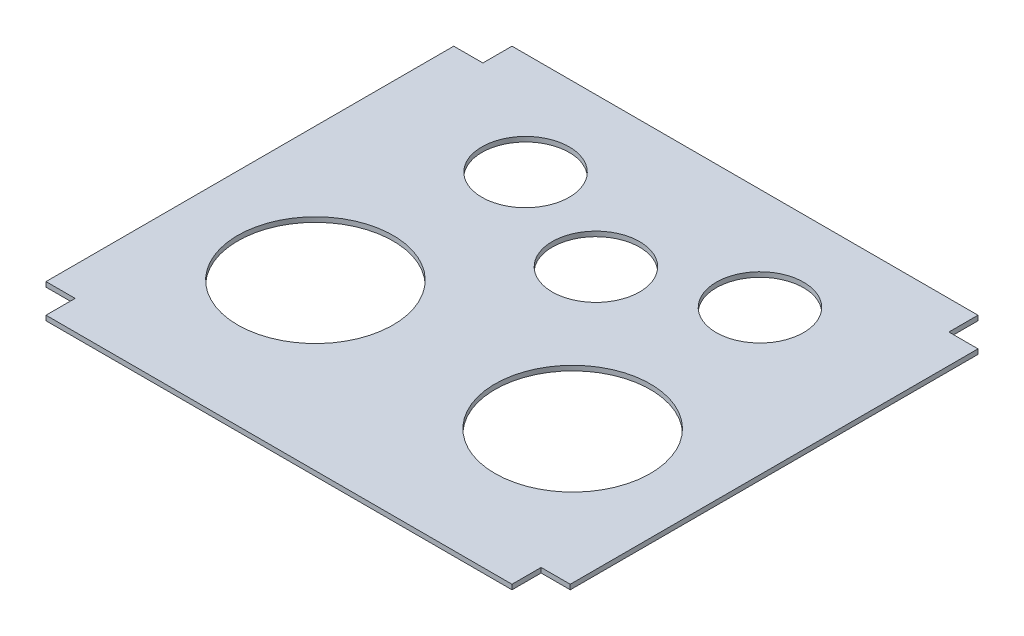
from build123d import *

# Parameters (mm, degrees)
SKETCH1_R           = 101.6
SKETCH1_R_2         = 57.15
BOSS_EXTRUDE1_DEPTH = 6.35


with BuildPart() as part:
    # Sketch1 → Boss-Extrude1 (new body)
    with BuildSketch(Plane(origin=(0, 0, 0), x_dir=(1, 0, 0), z_dir=(0, 1, 0))):
        Polygon((0, 0), (0, -38.1), (-609.6, -38.1), (-609.6, 0), (-647.7, 0), (-647.7, 533.4), (-609.6, 533.4), (-609.6, 571.5), (0, 571.5), (0, 533.4), (38.1, 533.4), (38.1, 0), align=None)
        with Locations((-473.075, 177.8)):
            Circle(SKETCH1_R, mode=Mode.SUBTRACT)
        with Locations((-136.525, 177.8)):
            Circle(SKETCH1_R, mode=Mode.SUBTRACT)
        with Locations((-304.8, 376.459625679)):
            Circle(SKETCH1_R_2, mode=Mode.SUBTRACT)
        with Locations((-151.485932589, 437.719781848)):
            Circle(SKETCH1_R_2, mode=Mode.SUBTRACT)
        with Locations((-458.114067411, 437.719781848)):
            Circle(SKETCH1_R_2, mode=Mode.SUBTRACT)
    extrude(amount=BOSS_EXTRUDE1_DEPTH)


solid = part.part
